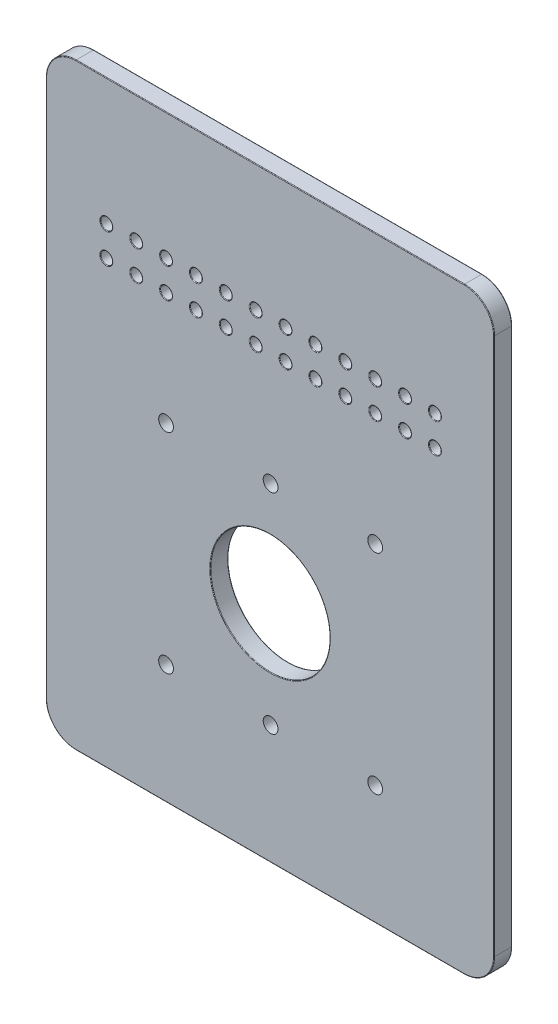
from build123d import *

# Parameters (mm, degrees)
SKETCH1_R           = 20
SKETCH1_R_2         = 2
SKETCH1_R_3         = 2.471995878
BOSS_EXTRUDE1_DEPTH = 3
FILLET2_R           = 0.2


with BuildPart() as part:
    # Sketch1 → Boss-Extrude1 (new body, symmetric)
    with BuildSketch(Plane.XY):
        with BuildLine():
            Line((-65, 125), (65, 125))
            ThreePointArc((65, 125), (72.071067812, 122.071067812), (75, 115))
            Line((75, 115), (75, -65))
            ThreePointArc((75, -65), (72.071067812, -72.071067812), (65, -75))
            Line((65, -75), (-65, -75))
            ThreePointArc((-65, -75), (-72.071067812, -72.071067812), (-75, -65))
            Line((-75, -65), (-75, 115))
            ThreePointArc((-75, 115), (-72.071067812, 122.071067812), (-65, 125))
        make_face()
        Circle(SKETCH1_R, mode=Mode.SUBTRACT)
        with Locations((-54.810125332, 72.662286143)):
            Circle(SKETCH1_R_2, mode=Mode.SUBTRACT)
        with Locations((-44.810125332, 72.662286143)):
            Circle(SKETCH1_R_2, mode=Mode.SUBTRACT)
        with Locations((-34.810125332, 72.662286143)):
            Circle(SKETCH1_R_2, mode=Mode.SUBTRACT)
        with Locations((-24.810125332, 72.662286143)):
            Circle(SKETCH1_R_2, mode=Mode.SUBTRACT)
        with Locations((-14.810125332, 72.662286143)):
            Circle(SKETCH1_R_2, mode=Mode.SUBTRACT)
        with Locations((-4.810125332, 72.662286143)):
            Circle(SKETCH1_R_2, mode=Mode.SUBTRACT)
        with Locations((5.189874668, 72.662286143)):
            Circle(SKETCH1_R_2, mode=Mode.SUBTRACT)
        with Locations((15.189874668, 72.662286143)):
            Circle(SKETCH1_R_2, mode=Mode.SUBTRACT)
        with Locations((25.189874668, 72.662286143)):
            Circle(SKETCH1_R_2, mode=Mode.SUBTRACT)
        with Locations((35.189874668, 72.662286143)):
            Circle(SKETCH1_R_2, mode=Mode.SUBTRACT)
        with Locations((45.189874668, 72.662286143)):
            Circle(SKETCH1_R_2, mode=Mode.SUBTRACT)
        with Locations((55.189874668, 72.662286143)):
            Circle(SKETCH1_R_2, mode=Mode.SUBTRACT)
        with Locations((-44.810125332, 82.662286143)):
            Circle(SKETCH1_R_2, mode=Mode.SUBTRACT)
        with Locations((-34.810125332, 82.662286143)):
            Circle(SKETCH1_R_2, mode=Mode.SUBTRACT)
        with Locations((-24.810125332, 82.662286143)):
            Circle(SKETCH1_R_2, mode=Mode.SUBTRACT)
        with Locations((-14.810125332, 82.662286143)):
            Circle(SKETCH1_R_2, mode=Mode.SUBTRACT)
        with Locations((-4.810125332, 82.662286143)):
            Circle(SKETCH1_R_2, mode=Mode.SUBTRACT)
        with Locations((5.189874668, 82.662286143)):
            Circle(SKETCH1_R_2, mode=Mode.SUBTRACT)
        with Locations((15.189874668, 82.662286143)):
            Circle(SKETCH1_R_2, mode=Mode.SUBTRACT)
        with Locations((25.189874668, 82.662286143)):
            Circle(SKETCH1_R_2, mode=Mode.SUBTRACT)
        with Locations((35.189874668, 82.662286143)):
            Circle(SKETCH1_R_2, mode=Mode.SUBTRACT)
        with Locations((45.189874668, 82.662286143)):
            Circle(SKETCH1_R_2, mode=Mode.SUBTRACT)
        with Locations((55.189874668, 82.662286143)):
            Circle(SKETCH1_R_2, mode=Mode.SUBTRACT)
        with Locations((-54.810125332, 82.662286143)):
            Circle(SKETCH1_R_2, mode=Mode.SUBTRACT)
        with Locations((35.189874668, 34.855141881)):
            Circle(SKETCH1_R_3, mode=Mode.SUBTRACT)
        with Locations((0.189874668, 34.855141881)):
            Circle(SKETCH1_R_3, mode=Mode.SUBTRACT)
        with Locations((-34.810125332, 34.855141881)):
            Circle(SKETCH1_R_3, mode=Mode.SUBTRACT)
        with Locations((0.189874668, -35.144858119)):
            Circle(SKETCH1_R_3, mode=Mode.SUBTRACT)
        with Locations((-34.810125332, -35.144858119)):
            Circle(SKETCH1_R_3, mode=Mode.SUBTRACT)
        with Locations((35.189874668, -35.144858119)):
            Circle(SKETCH1_R_3, mode=Mode.SUBTRACT)
    extrude(amount=BOSS_EXTRUDE1_DEPTH, both=True)

    # Fillet2
    fillet2_edges = [part.edges().sort_by_distance(p)[0] for p in [
        (33.189874668, 82.662286143, -3),
        (33.189874668, 82.662286143, 3),
        (-75, 25, -3),
        (43.189874668, 82.662286143, -3),
        (43.189874668, 82.662286143, 3),
        (-72.071067812, 122.071067812, -3),
        (53.189874668, 82.662286143, -3),
        (53.189874668, 82.662286143, 3),
        (0, 125, -3),
        (-56.810125332, 82.662286143, -3),
        (-56.810125332, 82.662286143, 3),
        (72.071067812, 122.071067812, -3),
        (-72.071067812, 122.071067812, 3),
        (-75, 25, 3),
        (-72.071067812, -72.071067812, 3),
        (-20, 0, -3),
        (-20, 0, 3),
        (0, -75, 3),
        (-56.810125332, 72.662286143, -3),
        (-56.810125332, 72.662286143, 3),
        (72.071067812, -72.071067812, 3),
        (-46.810125332, 72.662286143, -3),
        (-46.810125332, 72.662286143, 3),
        (75, 25, 3),
        (-36.810125332, 72.662286143, -3),
        (-36.810125332, 72.662286143, 3),
        (-26.810125332, 72.662286143, -3),
        (-26.810125332, 72.662286143, 3),
        (-16.810125332, 72.662286143, -3),
        (-16.810125332, 72.662286143, 3),
        (-6.810125332, 72.662286143, -3),
        (-6.810125332, 72.662286143, 3),
        (3.189874668, 72.662286143, -3),
        (3.189874668, 72.662286143, 3),
        (72.071067812, 122.071067812, 3),
        (13.189874668, 72.662286143, -3),
        (13.189874668, 72.662286143, 3),
        (23.189874668, 72.662286143, -3),
        (23.189874668, 72.662286143, 3),
        (33.189874668, 72.662286143, -3),
        (33.189874668, 72.662286143, 3),
        (43.189874668, 72.662286143, -3),
        (43.189874668, 72.662286143, 3),
        (53.189874668, 72.662286143, -3),
        (53.189874668, 72.662286143, 3),
        (-46.810125332, 82.662286143, -3),
        (-46.810125332, 82.662286143, 3),
        (-36.810125332, 82.662286143, -3),
        (-36.810125332, 82.662286143, 3),
        (-26.810125332, 82.662286143, -3),
        (-26.810125332, 82.662286143, 3),
        (-16.810125332, 82.662286143, -3),
        (-16.810125332, 82.662286143, 3),
        (75, 25, -3),
        (-6.810125332, 82.662286143, -3),
        (-6.810125332, 82.662286143, 3),
        (0, 125, 3),
        (72.071067812, -72.071067812, -3),
        (3.189874668, 82.662286143, -3),
        (3.189874668, 82.662286143, 3),
        (13.189874668, 82.662286143, -3),
        (0, -75, -3),
        (13.189874668, 82.662286143, 3),
        (23.189874668, 82.662286143, -3),
        (-72.071067812, -72.071067812, -3),
        (23.189874668, 82.662286143, 3),
    ]]
    fillet(fillet2_edges, radius=FILLET2_R)


solid = part.part
